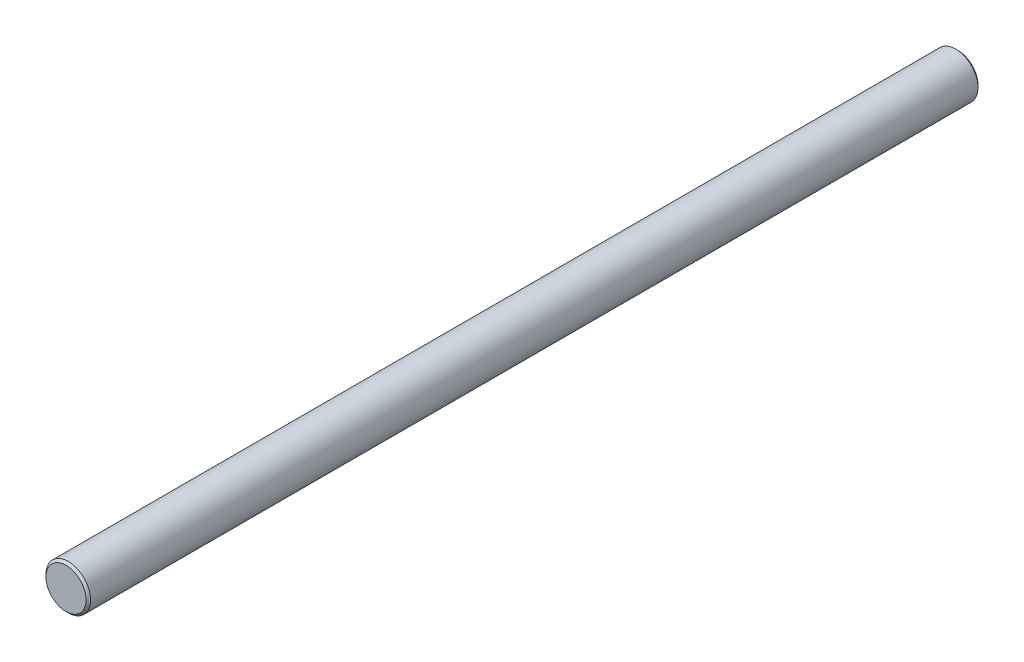
from build123d import *

# Parameters (mm, degrees)
SKETCH1_R           = 10
BOSS_EXTRUDE1_DEPTH = 400
CHAMFER1_SIZE       = 1
SKETCH2_R           = 3
CUT_EXTRUDE1_DEPTH  = 10
LPATTERN1_COUNT     = 3
LPATTERN1_PITCH     = 150


with BuildPart() as part:
    # Sketch1 → Boss-Extrude1 (new body)
    with BuildSketch(Plane.XY):
        Circle(SKETCH1_R)
    extrude(amount=BOSS_EXTRUDE1_DEPTH)

    # Chamfer1
    chamfer1_edges = [part.edges().sort_by_distance(p)[0] for p in [
        (-10, 0, 0),
        (-10, 0, 400),
    ]]
    chamfer(chamfer1_edges, length=CHAMFER1_SIZE)

    # Sketch2 → Cut-Extrude1 (cut)
    with BuildSketch(Plane(origin=(0, 0, 0), x_dir=(1, 0, 0), z_dir=(0, 1, 0))):
        with Locations((0, -15)):
            Circle(SKETCH2_R)
    cut_extrude1 = extrude(amount=-CUT_EXTRUDE1_DEPTH, mode=Mode.SUBTRACT)

    # LPattern1: Cut-Extrude1 ×3
    with Locations(*[(0, 0, i * LPATTERN1_PITCH) for i in range(1, LPATTERN1_COUNT)]):
        add(cut_extrude1, mode=Mode.SUBTRACT)


solid = part.part
